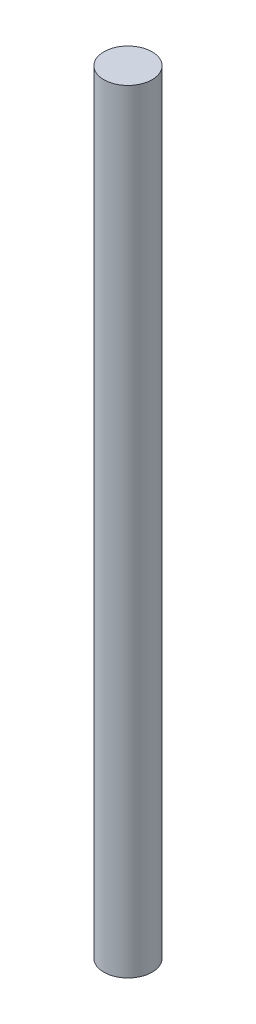
from build123d import *

# Parameters (mm, degrees)
IZIM1_R                     = 100
Y_KSEKLIK_EKSTR_ZYON1_DEPTH = 3200


with BuildPart() as part:
    # Çizim1 → Yükseklik-Ekstrüzyon1 (new body)
    with BuildSketch(Plane(origin=(0, 0, 0), x_dir=(1, 0, 0), z_dir=(0, 1, 0))):
        Circle(IZIM1_R)
    extrude(amount=Y_KSEKLIK_EKSTR_ZYON1_DEPTH)


solid = part.part
